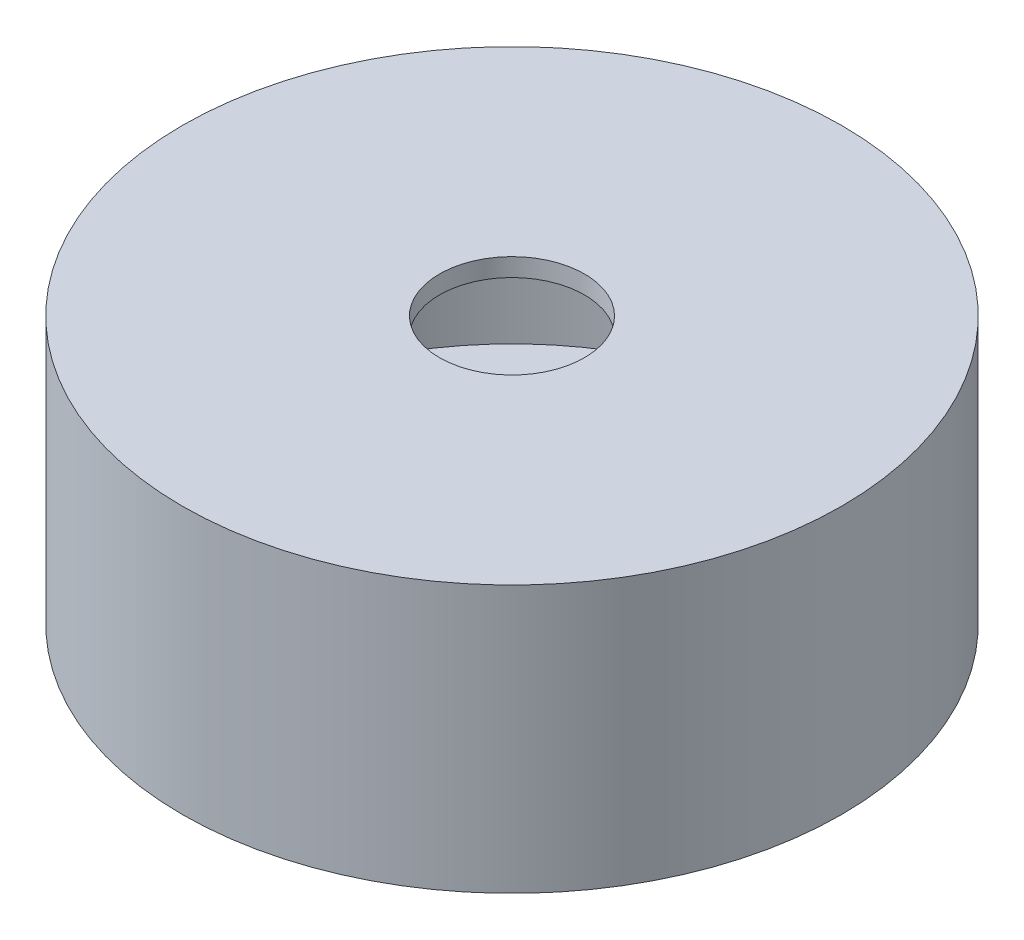
from build123d import *

# Parameters (mm, degrees)
SKETCH1_R           = 50
SKETCH1_W           = 60
SKETCH1_H           = 40
SKETCH1_W_2         = 45
SKETCH1_H_2         = 24.4
BOSS_EXTRUDE1_DEPTH = 5
CUT_EXTRUDE1_REACH  = 7
SKETCH8_R           = 1.025
SKETCH9_R           = 50
BOSS_EXTRUDE2_DEPTH = 32.75
SKETCH10_R          = 45
CUT_EXTRUDE2_DEPTH  = 32.75
SKETCH11_R          = 50
BOSS_EXTRUDE3_DEPTH = 2.75
SKETCH12_R          = 11
CUT_EXTRUDE3_DEPTH  = 2.75


with BuildPart() as part:
    # Sketch1 → Boss-Extrude1 (new body)
    with BuildSketch(Plane(origin=(0, 0, 0), x_dir=(1, 0, 0), z_dir=(0, 1, 0))):
        with Locations((17, 20)):
            Circle(SKETCH1_R)
        with Locations((30, 20)):
            Rectangle(SKETCH1_W, SKETCH1_H, mode=Mode.SUBTRACT)
        with Locations((30, 20)):
            Rectangle(SKETCH1_W, SKETCH1_H)
        with Locations((27.5, 20)):
            Rectangle(SKETCH1_W_2, SKETCH1_H_2, mode=Mode.SUBTRACT)
    extrude(amount=BOSS_EXTRUDE1_DEPTH)

    # Sketch8 → Cut-Extrude1 (cut, up to next)
    with BuildSketch(Plane(origin=(0, 0, 0), x_dir=(-1, 0, 0), z_dir=(0, -1, 0)), mode=Mode.PRIVATE) as cut_extrude1_sk1:
        with Locations((-52.8, 28.5)):
            Circle(SKETCH8_R)
    cut_extrude1_tool1 = extrude(cut_extrude1_sk1.sketch, amount=-CUT_EXTRUDE1_REACH, mode=Mode.PRIVATE) & part.part
    add(cut_extrude1_tool1.solids().sort_by_distance((52.8, 0, -28.5))[0], mode=Mode.SUBTRACT)
    # Sketch8 → Cut-Extrude1 (cut, up to next)
    with BuildSketch(Plane(origin=(0, 0, 0), x_dir=(-1, 0, 0), z_dir=(0, -1, 0)), mode=Mode.PRIVATE) as cut_extrude1_sk2:
        with Locations((-46.5, 35)):
            Circle(SKETCH8_R)
    cut_extrude1_tool2 = extrude(cut_extrude1_sk2.sketch, amount=-CUT_EXTRUDE1_REACH, mode=Mode.PRIVATE) & part.part
    add(cut_extrude1_tool2.solids().sort_by_distance((46.5, 0, -35))[0], mode=Mode.SUBTRACT)
    # Sketch8 → Cut-Extrude1 (cut, up to next)
    with BuildSketch(Plane(origin=(0, 0, 0), x_dir=(-1, 0, 0), z_dir=(0, -1, 0)), mode=Mode.PRIVATE) as cut_extrude1_sk3:
        with Locations((-29.5, 35)):
            Circle(SKETCH8_R)
    cut_extrude1_tool3 = extrude(cut_extrude1_sk3.sketch, amount=-CUT_EXTRUDE1_REACH, mode=Mode.PRIVATE) & part.part
    add(cut_extrude1_tool3.solids().sort_by_distance((29.5, 0, -35))[0], mode=Mode.SUBTRACT)
    # Sketch8 → Cut-Extrude1 (cut, up to next)
    with BuildSketch(Plane(origin=(0, 0, 0), x_dir=(-1, 0, 0), z_dir=(0, -1, 0)), mode=Mode.PRIVATE) as cut_extrude1_sk4:
        with Locations((-12.5, 35)):
            Circle(SKETCH8_R)
    cut_extrude1_tool4 = extrude(cut_extrude1_sk4.sketch, amount=-CUT_EXTRUDE1_REACH, mode=Mode.PRIVATE) & part.part
    add(cut_extrude1_tool4.solids().sort_by_distance((12.5, 0, -35))[0], mode=Mode.SUBTRACT)
    # Sketch8 → Cut-Extrude1 (cut, up to next)
    with BuildSketch(Plane(origin=(0, 0, 0), x_dir=(-1, 0, 0), z_dir=(0, -1, 0)), mode=Mode.PRIVATE) as cut_extrude1_sk5:
        with Locations((-12.5, 5)):
            Circle(SKETCH8_R)
    cut_extrude1_tool5 = extrude(cut_extrude1_sk5.sketch, amount=-CUT_EXTRUDE1_REACH, mode=Mode.PRIVATE) & part.part
    add(cut_extrude1_tool5.solids().sort_by_distance((12.5, 0, -5))[0], mode=Mode.SUBTRACT)
    # Sketch8 → Cut-Extrude1 (cut, up to next)
    with BuildSketch(Plane(origin=(0, 0, 0), x_dir=(-1, 0, 0), z_dir=(0, -1, 0)), mode=Mode.PRIVATE) as cut_extrude1_sk6:
        with Locations((-29.5, 5)):
            Circle(SKETCH8_R)
    cut_extrude1_tool6 = extrude(cut_extrude1_sk6.sketch, amount=-CUT_EXTRUDE1_REACH, mode=Mode.PRIVATE) & part.part
    add(cut_extrude1_tool6.solids().sort_by_distance((29.5, 0, -5))[0], mode=Mode.SUBTRACT)
    # Sketch8 → Cut-Extrude1 (cut, up to next)
    with BuildSketch(Plane(origin=(0, 0, 0), x_dir=(-1, 0, 0), z_dir=(0, -1, 0)), mode=Mode.PRIVATE) as cut_extrude1_sk7:
        with Locations((-46.5, 5)):
            Circle(SKETCH8_R)
    cut_extrude1_tool7 = extrude(cut_extrude1_sk7.sketch, amount=-CUT_EXTRUDE1_REACH, mode=Mode.PRIVATE) & part.part
    add(cut_extrude1_tool7.solids().sort_by_distance((46.5, 0, -5))[0], mode=Mode.SUBTRACT)
    # Sketch8 → Cut-Extrude1 (cut, up to next)
    with BuildSketch(Plane(origin=(0, 0, 0), x_dir=(-1, 0, 0), z_dir=(0, -1, 0)), mode=Mode.PRIVATE) as cut_extrude1_sk8:
        with Locations((-52.8, 11.5)):
            Circle(SKETCH8_R)
    cut_extrude1_tool8 = extrude(cut_extrude1_sk8.sketch, amount=-CUT_EXTRUDE1_REACH, mode=Mode.PRIVATE) & part.part
    add(cut_extrude1_tool8.solids().sort_by_distance((52.8, 0, -11.5))[0], mode=Mode.SUBTRACT)

    # Sketch9 → Boss-Extrude2 (add)
    with BuildSketch(Plane(origin=(0, 5, 0), x_dir=(1, 0, 0), z_dir=(0, 1, 0))):
        with Locations((17, 20)):
            Circle(SKETCH9_R)
    extrude(amount=BOSS_EXTRUDE2_DEPTH)

    # Sketch10 → Cut-Extrude2 (cut)
    with BuildSketch(Plane(origin=(0, 37.75, 0), x_dir=(1, 0, 0), z_dir=(0, 1, 0))):
        with Locations((17, 20)):
            Circle(SKETCH10_R)
    extrude(amount=-CUT_EXTRUDE2_DEPTH, mode=Mode.SUBTRACT)

    # Sketch11 → Boss-Extrude3 (add)
    with BuildSketch(Plane(origin=(0, 37.75, 0), x_dir=(1, 0, 0), z_dir=(0, 1, 0))):
        with Locations((17, 20)):
            Circle(SKETCH11_R)
    extrude(amount=BOSS_EXTRUDE3_DEPTH)

    # Sketch12 → Cut-Extrude3 (cut)
    with BuildSketch(Plane(origin=(0, 40.5, 0), x_dir=(1, 0, 0), z_dir=(0, 1, 0))):
        with Locations((17, 20)):
            Circle(SKETCH12_R)
    extrude(amount=-CUT_EXTRUDE3_DEPTH, mode=Mode.SUBTRACT)


solid = part.part
